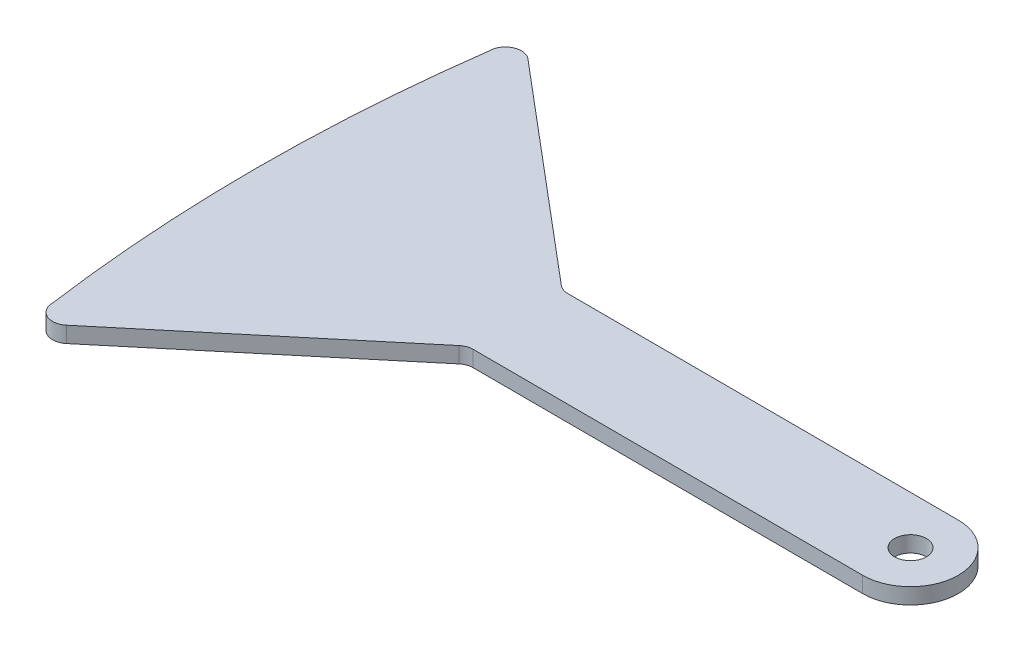
from build123d import *

# Parameters (mm, degrees)
SKETCH1_R           = 1
BOSS_EXTRUDE3_DEPTH = 1
SKETCH3_R           = 1
BOSS_EXTRUDE4_DEPTH = 1


with BuildPart() as part:
    # Sketch1 → Boss-Extrude3 (new body)
    with BuildSketch(Plane(origin=(0, 0, 0), x_dir=(1, 0, 0), z_dir=(0, 1, 0))):
        with BuildLine():
            Line((0.435948957, 3.056735566), (25.006928102, 2.999992))
            ThreePointArc((25.006928102, 2.999992), (27.999992, -0.006928102), (24.993071898, -2.999992))
            Line((24.993071898, -2.999992), (0.495326263, -2.943417558))
            ThreePointArc((0.495326263, -2.943417558), (0.15316776, -3.002934926), (-0.147999921, -3.175888058))
            Line((-0.147999921, -3.175888058), (-13.578162843, -14.392382292))
            ThreePointArc((-13.578162843, -14.392382292), (-14.642844141, -14.530674651), (-15.219179661, -13.624855459))
            ThreePointArc((-15.219179661, -13.624855459), (-16.155963413, 0.086416086), (-15.219179661, 13.797687632))
            ThreePointArc((-15.219179661, 13.797687632), (-14.640751142, 14.704482805), (-13.574624688, 14.562245599))
            Line((-13.574624688, 14.562245599), (-0.206296649, 3.292174932))
            ThreePointArc((-0.206296649, 3.292174932), (0.094068998, 3.117832635), (0.435948957, 3.056735566))
        make_face()
        with Locations((25, 0)):
            Circle(SKETCH1_R, mode=Mode.SUBTRACT)
    extrude(amount=BOSS_EXTRUDE3_DEPTH)

    # Sketch3 → Boss-Extrude4 (add)
    with BuildSketch(Plane.XZ):
        Circle(SKETCH3_R)
    extrude(amount=BOSS_EXTRUDE4_DEPTH)


solid = part.part
